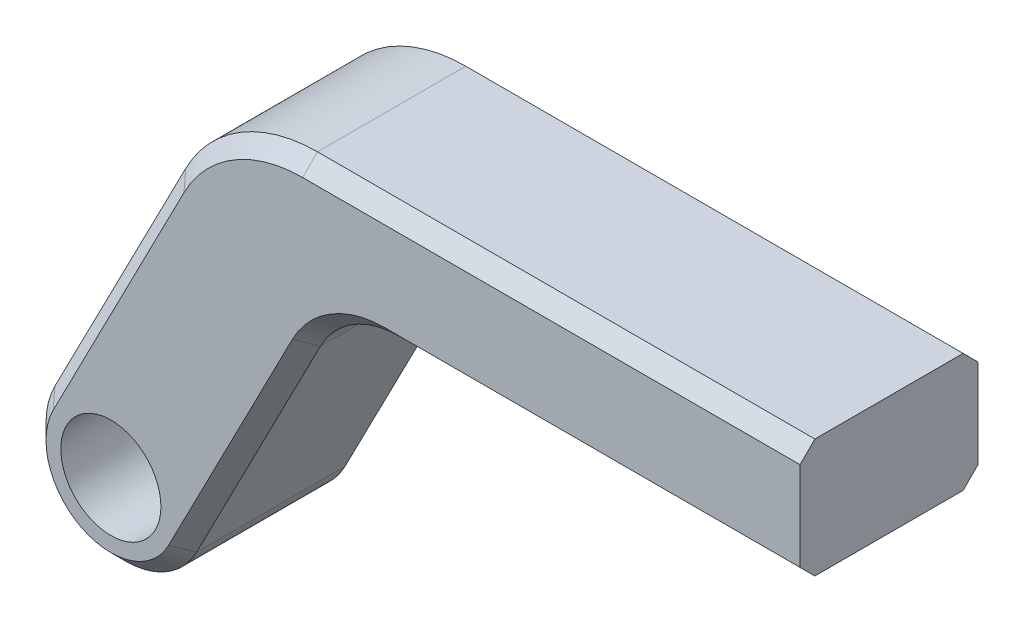
from build123d import *
from OCP.BRepFilletAPI import BRepFilletAPI_MakeFillet

# Parameters (mm, degrees)
SKETCH1_R           = 3.375
BOSS_EXTRUDE1_DEPTH = 12
FILLET1_R1          = 10
FILLET1_R2          = 6
CHAMFER1_SIZE       = 1


with BuildPart() as part:
    # Sketch1 → Boss-Extrude1 (new body)
    with BuildSketch(Plane.XY):
        with BuildLine():
            Line((6.836003543, 25), (-4.777935452, 2.462104347))
            ThreePointArc((-4.777935452, 2.462104347), (-2.462104347, -4.777935452), (4.777935452, -2.462104347))
            Line((4.777935452, -2.462104347), (14.806897165, 17))
            Line((14.806897165, 17), (46.473934517, 17))
            Line((46.473934517, 17), (46.473934517, 25))
            Line((46.473934517, 25), (6.836003543, 25))
        make_face()
        Circle(SKETCH1_R, mode=Mode.SUBTRACT)
    extrude(amount=BOSS_EXTRUDE1_DEPTH)

    # Fillet1: one fillet with a radius per group of edges: ONE call of the kernel's fillet builder (fillet() takes one radius for all edges)
    fillet1_edges_1 = [part.edges().sort_by_distance(p)[0] for p in [
        (6.836003543, 25, 6),
    ]]
    fillet1_edges_2 = [part.edges().sort_by_distance(p)[0] for p in [
        (14.806897165, 17, 6),
    ]]
    fillet1 = BRepFilletAPI_MakeFillet(part.part.solid().wrapped)
    for e in fillet1_edges_1:
        fillet1.Add(FILLET1_R1, e.wrapped)
    for e in fillet1_edges_2:
        fillet1.Add(FILLET1_R2, e.wrapped)
    add(Compound.cast(fillet1.Shape()), mode=Mode.REPLACE)

    # Chamfer1
    chamfer1_edges = [part.edges().sort_by_distance(p)[0] for p in [
        (32.469382985, 17, 0),
        (15.341561797, 16.123005627, 0),
        (8.954628782, 5.643145602, 0),
        (-2.462104347, -4.777935452, 0),
        (-0.367278499, 11.021381799, 0),
        (7.727111262, 23.538342711, 0),
        (29.703247603, 25, 0),
        (32.469382985, 17, 12),
        (15.341561797, 16.123005627, 12),
        (8.954628782, 5.643145602, 12),
        (-2.462104347, -4.777935452, 12),
        (-0.367278499, 11.021381799, 12),
        (7.727111262, 23.538342711, 12),
        (29.703247603, 25, 12),
    ]]
    chamfer(chamfer1_edges, length=CHAMFER1_SIZE)


solid = part.part
